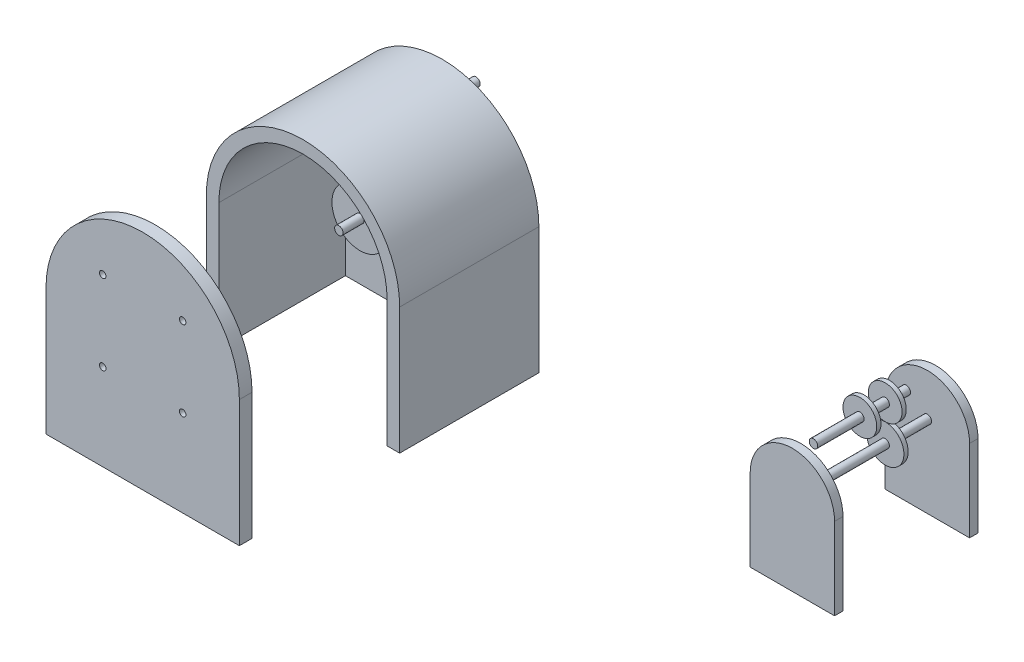
from build123d import *

# Parameters (mm, degrees)
BOSS_EXTRUDE1_DEPTH       = 3
BOSS_EXTRUDE1_2_DEPTH     = 3
BOSS_EXTRUDE1_3_DEPTH     = 3
BOSS_EXTRUDE1_4_DEPTH     = 3
SKETCH1_R                 = 22.916835629
BOSS_EXTRUDE1_5_DEPTH     = 3
SKETCH2_R                 = 1.398373037
SKETCH2_R_2               = 1
BOSS_EXTRUDE2_DEPTH       = 8
SKETCH3_R                 = 22.916835629
SKETCH3_R_2               = 19.942015488
BOSS_EXTRUDE4_DEPTH       = 30
CUT_EXTRUDE1_DEPTH        = 30
SKETCH5_W                 = 2.974820141
SKETCH5_H                 = 33
BOSS_EXTRUDE5_DEPTH       = 30
BOSS_EXTRUDE6_REACH       = 68.441
BOSS_EXTRUDE6_END_RADIUS  = 22.916835629
SKETCH6_W                 = 45.833671258
SKETCH6_H                 = 3
BOSS_EXTRUDE8_DEPTH       = 1.5
BOSS_EXTRUDE8_DEPTH_BACK  = 1.5
SKETCH7_R                 = 6.640420206
SKETCH9_R                 = 1
BOSS_EXTRUDE9_DEPTH       = 5
BOSS_EXTRUDE10_DEPTH      = 3
SKETCH11_R                = 0.768146355
CUT_EXTRUDE2_DEPTH        = 5
SKETCH12_R                = 4
BOSS_EXTRUDE11_DEPTH      = 1
BOSS_EXTRUDE12_DEPTH      = 11
BOSS_EXTRUDE12_DEPTH_BACK = 11
SKETCH13_R                = 1
SKETCH14_R                = 4
BOSS_EXTRUDE13_DEPTH      = 1
SKETCH15_R                = 4.43894644
BOSS_EXTRUDE14_DEPTH      = 1
BOSS_EXTRUDE15_DEPTH      = 20
BOSS_EXTRUDE15_DEPTH_BACK = 10
SKETCH16_R                = 1
BOSS_EXTRUDE17_DEPTH      = 2


with BuildPart() as part:
    # Sketch1 → Boss-Extrude1 (new body)
    with BuildSketch(Plane.XY):
        with BuildLine():
            ThreePointArc((8.868684316, -5.120338679), (8.868685222, 5.120337109), (-1.7e-08, 10.240675255))
            ThreePointArc((-1.7e-08, 10.240675255), (-8.868684145, 5.120338974), (-8.868686486, -5.12033492))
            ThreePointArc((-8.868686486, -5.12033492), (-2.17e-06, -10.240675255), (8.868684316, -5.120338679))
        make_face()
    extrude(amount=BOSS_EXTRUDE1_DEPTH)



with BuildPart() as body_2:
    # Sketch1 → Boss-Extrude1 2 (new body)
    with BuildSketch(Plane.XY):
        with BuildLine():
            ThreePointArc((-6.7e-08, 18.361415927), (-4.060370336, 14.301045566), (-1.7e-08, 10.240675255))
            ThreePointArc((-1.7e-08, 10.240675255), (4.060370336, 14.301045616), (-6.7e-08, 18.361415927))
        make_face()
    extrude(amount=BOSS_EXTRUDE1_2_DEPTH)


with BuildPart() as body_3:
    # Sketch1 → Boss-Extrude1 3 (new body)
    with BuildSketch(Plane.XY):
        with BuildLine():
            ThreePointArc((15.901454481, -9.180704779), (14.415251833, -3.634137713), (8.868684316, -5.120338679))
            ThreePointArc((8.868684316, -5.120338679), (10.354885732, -10.666907878), (15.901454481, -9.180704779))
        make_face()
    extrude(amount=BOSS_EXTRUDE1_3_DEPTH)


with BuildPart() as body_4:
    # Sketch1 → Boss-Extrude1 4 (new body)
    with BuildSketch(Plane.XY):
        with BuildLine():
            ThreePointArc((-15.901453923, -9.180705744), (-10.35488337, -10.666906514), (-8.868686486, -5.12033492))
            ThreePointArc((-8.868686486, -5.12033492), (-14.415254195, -3.634139077), (-15.901453923, -9.180705744))
        make_face()
    extrude(amount=BOSS_EXTRUDE1_4_DEPTH)


with BuildPart() as body_5:
    # Sketch1 → Boss-Extrude1 5 (new body)
    with BuildSketch(Plane.XY):
        Circle(SKETCH1_R)
        with BuildLine():
            ThreePointArc((-15.901453923, -9.180705744), (-15.901452018, 9.180709044), (-6.7e-08, 18.361415927))
            ThreePointArc((-6.7e-08, 18.361415927), (15.901451706, 9.180709585), (15.901454481, -9.180704779))
            ThreePointArc((15.901454481, -9.180704779), (5.57e-07, -18.361415927), (-15.901453923, -9.180705744))
        make_face(mode=Mode.SUBTRACT)
    extrude(amount=BOSS_EXTRUDE1_5_DEPTH)

    # Sketch3 → Boss-Extrude4 (add)
    with BuildSketch(Plane.XY.offset(3)):
        Circle(SKETCH3_R)
        Circle(SKETCH3_R_2, mode=Mode.SUBTRACT)
    extrude(amount=BOSS_EXTRUDE4_DEPTH)

    # Sketch4 → Cut-Extrude1 (cut)
    with BuildSketch(Plane.XY.offset(33)):
        with BuildLine():
            Line((0, 0), (22.916835629, 0))
            ThreePointArc((22.916835629, 0), (0, -22.916835629), (-22.916835629, 0))
            Line((-22.916835629, 0), (0, 0))
        make_face()
    extrude(amount=-CUT_EXTRUDE1_DEPTH, mode=Mode.SUBTRACT)

    # Sketch5 → Boss-Extrude5 (add)
    with BuildSketch(Plane.XZ):
        with Locations((-21.429425559, 16.5)):
            Rectangle(SKETCH5_W, SKETCH5_H)
        with Locations((21.429425559, 16.5)):
            Rectangle(SKETCH5_W, SKETCH5_H)
    extrude(amount=BOSS_EXTRUDE5_DEPTH)

    # Boss-Extrude6: up to this cylinder (the profile starts outside it)
    boss_extrude6_end = Plane(origin=(0, 0, 1.5), z_dir=(0, 0, -1)) * Cylinder(BOSS_EXTRUDE6_END_RADIUS, 183.715671258, mode=Mode.PRIVATE)
    # Sketch6 → Boss-Extrude6 (add, up to the surface)
    with BuildSketch(Plane.XZ.offset(30), mode=Mode.PRIVATE) as boss_extrude6_sk1:
        with Locations((0, 1.5)):
            Rectangle(SKETCH6_W, SKETCH6_H)
    boss_extrude6_tool1 = extrude(boss_extrude6_sk1.sketch, amount=-BOSS_EXTRUDE6_REACH, mode=Mode.PRIVATE) - boss_extrude6_end
    add(boss_extrude6_tool1.solids().sort_by_distance((0, -30, 1.5))[0])


with BuildPart() as part_1:
    add(part.part)

    add(body_2.part)  # Boss-Extrude2 merges body 2

    add(body_3.part)  # Boss-Extrude2 merges body 3

    add(body_4.part)  # Boss-Extrude2 merges body 4
    # Sketch2 → Boss-Extrude2 (add)
    with BuildSketch(Plane(origin=(0, 0, 0), x_dir=(-1, 0, 0), z_dir=(0, 0, -1))):
        Circle(SKETCH2_R)
        with Locations((0, 14.301045591)):
            Circle(SKETCH2_R_2)
        with Locations((12.385068782, -7.150522795)):
            Circle(SKETCH2_R_2)
        with Locations((-12.385068782, -7.150522795)):
            Circle(SKETCH2_R_2)
    extrude(amount=BOSS_EXTRUDE2_DEPTH)


with BuildPart() as body_3_2:
    # Sketch7 → Boss-Extrude8 (new, two sides: drawn at the far end of the back side and taken through both)
    with BuildSketch(Plane.XY.offset(18).offset(-BOSS_EXTRUDE8_DEPTH_BACK)):
        Circle(SKETCH7_R)
    extrude(amount=BOSS_EXTRUDE8_DEPTH + BOSS_EXTRUDE8_DEPTH_BACK)

    # Sketch9 → Boss-Extrude9 (add)
    with BuildSketch(Plane.XY.offset(19.5)):
        Circle(SKETCH9_R)
    extrude(amount=BOSS_EXTRUDE9_DEPTH)


with BuildPart() as body_4_2:
    # Sketch10 → Boss-Extrude10 (new body)
    with BuildSketch(Plane.XY.offset(68)):
        with BuildLine():
            Line((22.916835629, -30), (22.916835629, 0))
            ThreePointArc((22.916835629, 0), (0, 22.916835629), (-22.916835629, 0))
            Line((-22.916835629, 0), (-22.916835629, -30))
            Line((-22.916835629, -30), (22.916835629, -30))
        make_face()
    extrude(amount=BOSS_EXTRUDE10_DEPTH)

    # Sketch11 → Cut-Extrude2 (cut)
    with BuildSketch(Plane.XY.offset(71)):
        with Locations((9.470964869, 9.470964869)):
            Circle(SKETCH11_R)
        with Locations((9.470964869, -9.470964869)):
            Circle(SKETCH11_R)
        with Locations((-9.470964869, -9.470964869)):
            Circle(SKETCH11_R)
        with Locations((-9.470964869, 9.470964869)):
            Circle(SKETCH11_R)
    extrude(amount=-CUT_EXTRUDE2_DEPTH, mode=Mode.SUBTRACT)


with BuildPart() as body_5_2:
    # Sketch12 → Boss-Extrude11 (new body)
    with BuildSketch(Plane.XY):
        with Locations((100, 0)):
            Circle(SKETCH12_R)
    extrude(amount=BOSS_EXTRUDE11_DEPTH)

    # Sketch13 → Boss-Extrude12 (add, two sides: drawn at the far end of the back side and taken through both)
    with BuildSketch(Plane.XY.offset(1).offset(-BOSS_EXTRUDE12_DEPTH_BACK)):
        with Locations((100, 0)):
            Circle(SKETCH13_R)
    extrude(amount=BOSS_EXTRUDE12_DEPTH + BOSS_EXTRUDE12_DEPTH_BACK)

    # Sketch14 → Boss-Extrude13 (add)
    with BuildSketch(Plane(origin=(0, 0, -5), x_dir=(-1, 0, 0), z_dir=(0, 0, -1))):
        with Locations((-100, 0)):
            Circle(SKETCH14_R)
    extrude(amount=BOSS_EXTRUDE13_DEPTH)


with BuildPart() as body_6:
    # Sketch15 → Boss-Extrude14 (new body)
    with BuildSketch(Plane(origin=(0, 0, -5), x_dir=(-1, 0, 0), z_dir=(0, 0, -1))):
        with Locations((-100, -8.456155951)):
            Circle(SKETCH15_R)
    extrude(amount=BOSS_EXTRUDE14_DEPTH)

    # Sketch16 → Boss-Extrude15 (add, two sides: drawn at the far end of the back side and taken through both)
    with BuildSketch(Plane.XY.offset(-5).offset(-BOSS_EXTRUDE15_DEPTH_BACK)):
        with Locations((100, -8.456155951)):
            Circle(SKETCH16_R)
    extrude(amount=BOSS_EXTRUDE15_DEPTH + BOSS_EXTRUDE15_DEPTH_BACK)

    # Sketch17 → Boss-Extrude17 (add)
    with BuildSketch(Plane.XY.offset(15)):
        with BuildLine():
            ThreePointArc((110, -8.456155951), (100, 1.543844049), (90, -8.456155951))
            Line((90, -8.456155951), (90, -27.854411682))
            Line((90, -27.854411682), (110, -27.854411682))
            Line((110, -27.854411682), (110, -8.456155951))
        make_face()
    boss_extrude17 = extrude(amount=BOSS_EXTRUDE17_DEPTH)

    # Mirror1: Boss-Extrude17 across plane
    add(boss_extrude17.mirror(Plane.XY))


solid = Compound([body_5.part, part_1.part, body_3_2.part, body_4_2.part, body_5_2.part, body_6.part])
